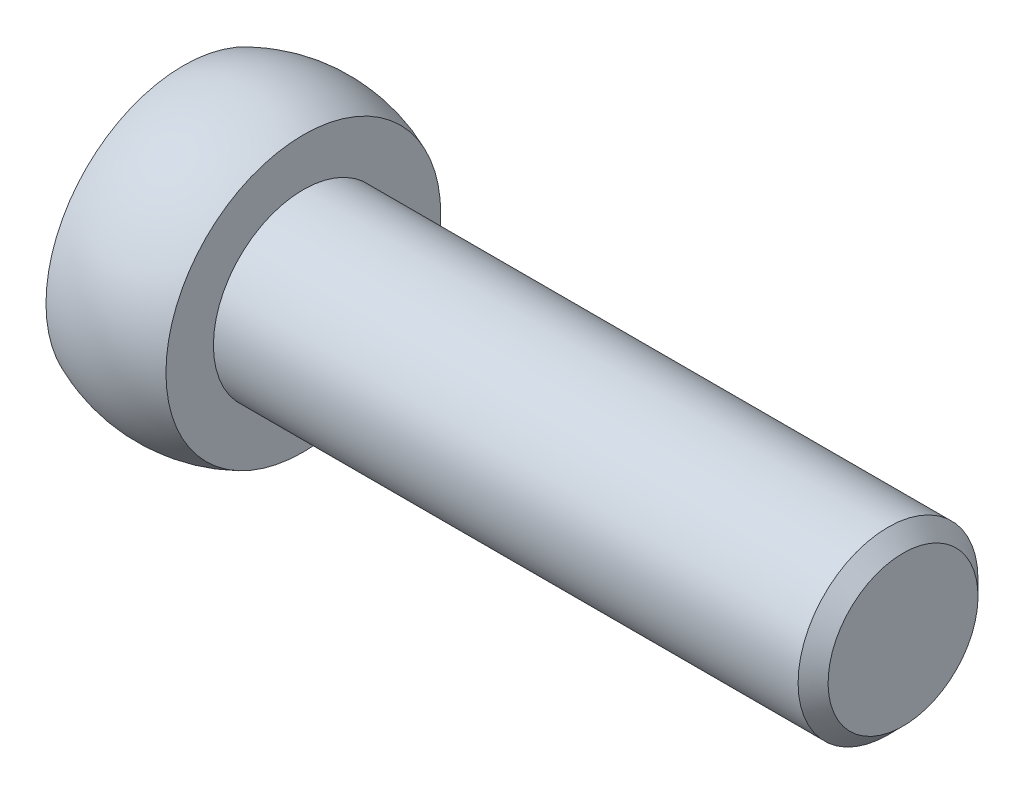
from build123d import *


with BuildPart() as part:
    # Эскиз1 → Повернуть1 (revolve)
    with BuildSketch(Plane.XY):
        with BuildLine():
            Line((0, 0), (0, 4.582575695))
            ThreePointArc((0, 4.582575695), (2, 5), (4, 4.582575695))
            Line((4, 4.582575695), (4, 3))
            Line((4, 3), (23.5, 3))
            Line((23.5, 3), (24, 2.5))
            Line((24, 2.5), (24, 0))
            Line((24, 0), (0, 0))
        make_face()
    revolve(axis=Axis((0, 0, 0), (-1, 0, 0)))


solid = part.part
